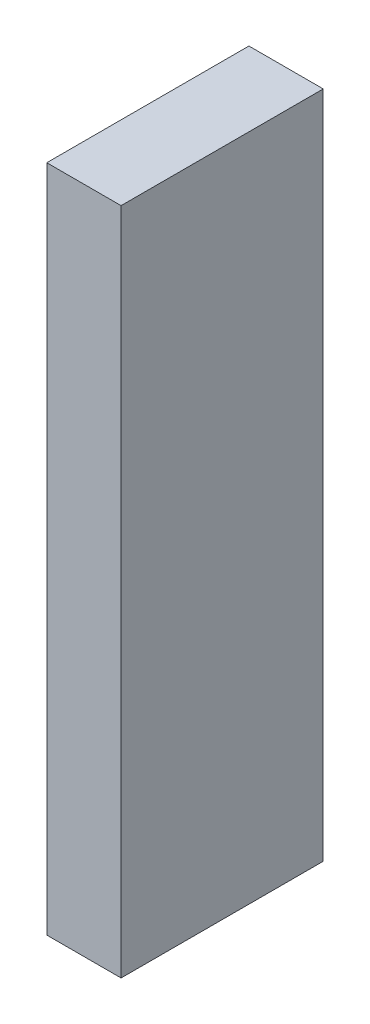
from build123d import *

# Parameters (mm, degrees)
SKETCH1_W           = 8.636
SKETCH1_H           = 28.575
BOSS_EXTRUDE1_DEPTH = 3.175


with BuildPart() as part:
    # Sketch1 → Boss-Extrude1 (new body)
    with BuildSketch(Plane(origin=(0, 0, 0), x_dir=(0, 0, -1), z_dir=(1, 0, 0))):
        Rectangle(SKETCH1_W, SKETCH1_H)
    extrude(amount=BOSS_EXTRUDE1_DEPTH)


solid = part.part
